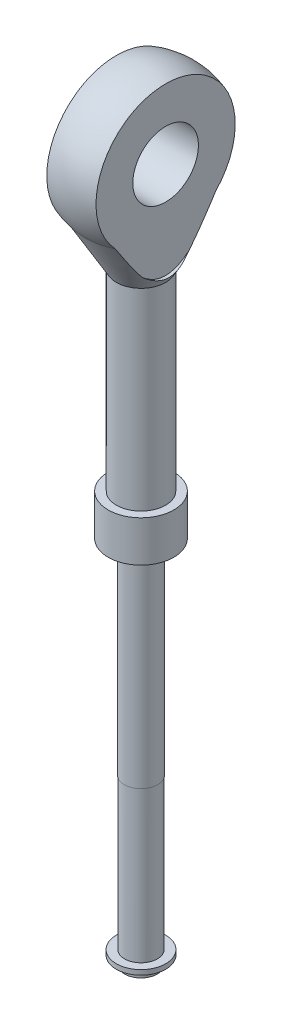
from build123d import *

# Parameters (mm, degrees)
SZKIC2_W                    = 5.611911117
SZKIC2_H                    = 18
WYTNIJ_WYCI_GNI_CIE3_DEPTH  = 200
SZKIC3_R                    = 4
WYTNIJ_WYCI_GNI_CIE4_DEPTH  = 9
WYTNIJ_WYCI_GNI_CIE5_DEPTH  = 1
SZKIC5_R                    = 2.025
DODANIE_WYCI_GNI_CIE1_DEPTH = 25


with BuildPart() as part:
    # Szkic1 → Obrót1 (revolve)
    with BuildSketch(Plane.XY):
        with BuildLine():
            Line((0, 0), (-2, 0))
            Line((-2, 0), (-2, 1.009242946))
            Line((-2, 1.009242946), (-3.014835025, 1.009242946))
            Line((-3.014835025, 1.009242946), (-3.014835025, 1.600524218))
            Line((-3.014835025, 1.600524218), (-2, 1.600524218))
            Line((-2, 1.600524218), (-2, 45))
            Line((-2, 45), (-4, 45))
            Line((-4, 45), (-4, 50))
            Line((-4, 50), (-3, 50))
            Line((-3, 50), (-3, 73.52))
            Line((-3, 73.52), (-6.811196546, 80.121186056))
            ThreePointArc((-6.811196546, 80.121186056), (-8.18368509, 89.74931215), (0, 95.004008644))
            Line((0, 95.004008644), (0, 88.504008644))
            ThreePointArc((0, 88.504008644), (-2.5, 86.004008644), (0, 83.504008644))
            Line((0, 83.504008644), (0, 0))
        make_face()
    revolve(axis=Axis((0, 83.504008644, 0), (0, -1, 0)))

    # Szkic2 → Wytnij-wyciągnięcie3 (cut)
    with BuildSketch(Plane(origin=(0, 0, 0), x_dir=(1, 0, 0), z_dir=(0, 1, 0))):
        with Locations((-6.805955559, 0)):
            Rectangle(SZKIC2_W, SZKIC2_H)
        with Locations((6.805955559, 0)):
            Rectangle(SZKIC2_W, SZKIC2_H)
    extrude(amount=WYTNIJ_WYCI_GNI_CIE3_DEPTH, mode=Mode.SUBTRACT)

    # Szkic3 → Wytnij-wyciągnięcie4 (cut, through all)
    with BuildSketch(Plane.ZY.offset(4)):
        with Locations((0, 86.004008644)):
            Circle(SZKIC3_R)
    extrude(amount=-WYTNIJ_WYCI_GNI_CIE4_DEPTH, mode=Mode.SUBTRACT)

    # Szkic4 → Wytnij-wyciągnięcie5 (cut)
    with BuildSketch(Plane.ZY.offset(4)):
        with BuildLine():
            ThreePointArc((6.270693727, 79.461614917), (-1.54e-07, 95.066266393), (-6.270693505, 79.461614705))
            add(Edge.make_bspline(
                [(-6.270693505, 79.461614705), (-5.860155238, 78.888013675), (-5.439822901, 78.322282195), (-4.56334323, 77.21959664), (-4.106381954, 76.681557874), (-3.363374021, 75.926338216), (-3.10680463, 75.684743321), (-2.565651322, 75.233486624), (-2.278481074, 75.02263049), (-1.674076312, 74.662473364), (-1.356546022, 74.513041633), (-0.676664628, 74.303793525), (-0.328815369, 74.249380941), (0.202925796, 74.253535488), (0.380729476, 74.269527018), (0.727839454, 74.32754423), (0.898553898, 74.369864163), (1.234860958, 74.478505876), (1.400715996, 74.545180561), (1.719331355, 74.695600019), (1.873358854, 74.779672361), (2.32266111, 75.053340603), (2.606912587, 75.265451803), (3.145505929, 75.720013642), (3.399015103, 75.960994151), (4.130320647, 76.709293024), (4.580547786, 77.240534568), (5.447234702, 78.332319258), (5.863652605, 78.892898741), (6.270693727, 79.461614917)],
                knots=[0, 0, 0, 0, 0.125, 0.125, 0.25, 0.25, 0.3125, 0.3125, 0.375, 0.375, 0.4375, 0.4375, 0.5, 0.5, 0.53125, 0.53125, 0.5625, 0.5625, 0.59375, 0.59375, 0.625, 0.625, 0.6875, 0.6875, 0.75, 0.75, 0.875, 0.875, 1, 1, 1, 1], degree=3))
        make_face()
    wytnij_wyci_gni_cie5 = extrude(amount=-WYTNIJ_WYCI_GNI_CIE5_DEPTH, mode=Mode.SUBTRACT)

    # Lustro1: Wytnij-wyciągnięcie5 across plane
    add(wytnij_wyci_gni_cie5.mirror(Plane(origin=(0, 0, 0), x_dir=(0, 0, 1), z_dir=(1, 0, 0))), mode=Mode.SUBTRACT)

    # Szkic5 → Dodanie-wyciągnięcie1 (add)
    with BuildSketch(Plane.XZ.offset(-45)):
        Circle(SZKIC5_R)
    extrude(amount=DODANIE_WYCI_GNI_CIE1_DEPTH)


solid = part.part
